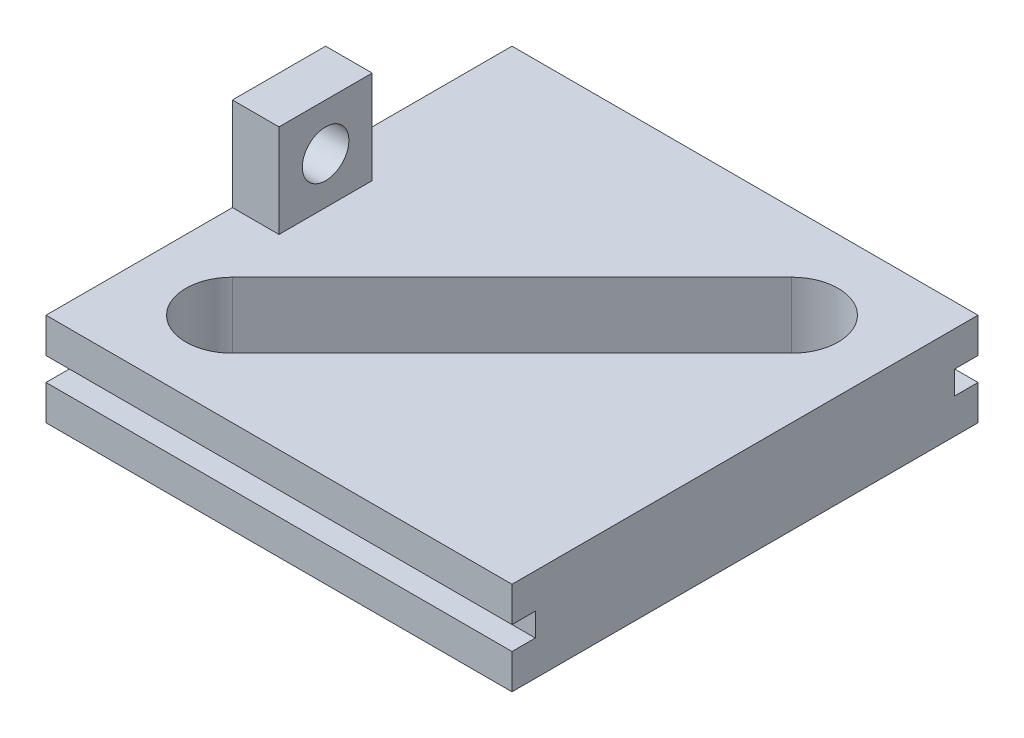
from build123d import *

# Parameters (mm, degrees)
SKETCH1_W           = 63.5
SKETCH1_H           = 63.5
BOSS_EXTRUDE1_DEPTH = 12.7
SKETCH2_W           = 63.5
SKETCH2_H           = 3.175
CUT_EXTRUDE1_DEPTH  = 3.175
SKETCH3_W           = 6.35
SKETCH3_H           = 12.7
BOSS_EXTRUDE2_DEPTH = 12.7
SKETCH4_R           = 3.175
CUT_EXTRUDE2_DEPTH  = 64.5


with BuildPart() as part:
    # Sketch1 → Boss-Extrude1 (new body)
    with BuildSketch(Plane(origin=(0, 0, 0), x_dir=(1, 0, 0), z_dir=(0, 1, 0))):
        Rectangle(SKETCH1_W, SKETCH1_H)
        with BuildLine():
            Line((-23.540128061, -14.559871939), (14.559871939, 23.540128061))
            ThreePointArc((14.559871939, 23.540128061), (23.540128061, 23.540128061), (23.540128061, 14.559871939))
            Line((23.540128061, 14.559871939), (-14.559871939, -23.540128061))
            ThreePointArc((-14.559871939, -23.540128061), (-23.540128061, -23.540128061), (-23.540128061, -14.559871939))
        make_face(mode=Mode.SUBTRACT)
    extrude(amount=BOSS_EXTRUDE1_DEPTH)

    # Sketch2 → Cut-Extrude1 (cut)
    with BuildSketch(Plane.XY.offset(31.75)):
        with Locations((0, 6.35)):
            Rectangle(SKETCH2_W, SKETCH2_H)
    cut_extrude1 = extrude(amount=-CUT_EXTRUDE1_DEPTH, mode=Mode.SUBTRACT)

    # Mirror1: Cut-Extrude1 across plane
    add(cut_extrude1.mirror(Plane.XY), mode=Mode.SUBTRACT)

    # Sketch3 → Boss-Extrude2 (add)
    with BuildSketch(Plane(origin=(0, 12.7, 0), x_dir=(1, 0, 0), z_dir=(0, 1, 0))):
        with Locations((-28.575, 0)):
            Rectangle(SKETCH3_W, SKETCH3_H)
    extrude(amount=BOSS_EXTRUDE2_DEPTH)

    # Sketch4 → Cut-Extrude2 (cut, through all)
    with BuildSketch(Plane.ZY.offset(31.75)):
        with Locations((0, 19.05)):
            Circle(SKETCH4_R)
    extrude(amount=-CUT_EXTRUDE2_DEPTH, mode=Mode.SUBTRACT)


solid = part.part
